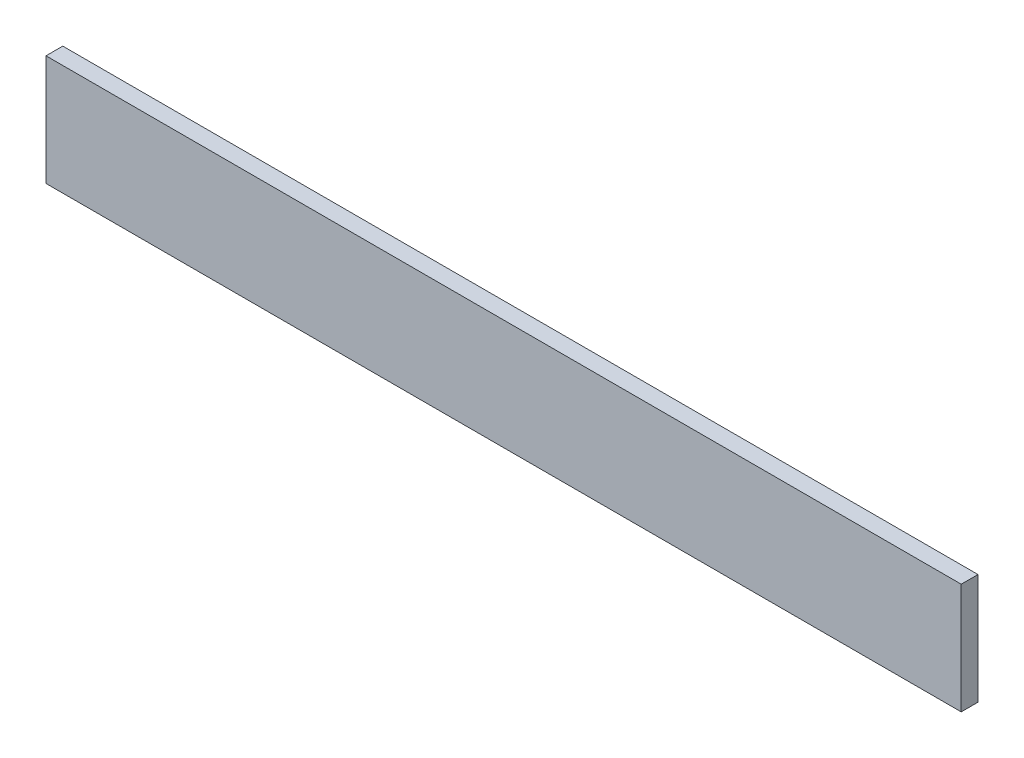
from build123d import *

# Parameters (mm, degrees)
SKETCH1_W           = 1200
SKETCH1_H           = 145
BOSS_EXTRUDE1_DEPTH = 22


with BuildPart() as part:
    # Sketch1 → Boss-Extrude1 (new body)
    with BuildSketch(Plane.XY):
        Rectangle(SKETCH1_W, SKETCH1_H)
    extrude(amount=BOSS_EXTRUDE1_DEPTH)


solid = part.part
